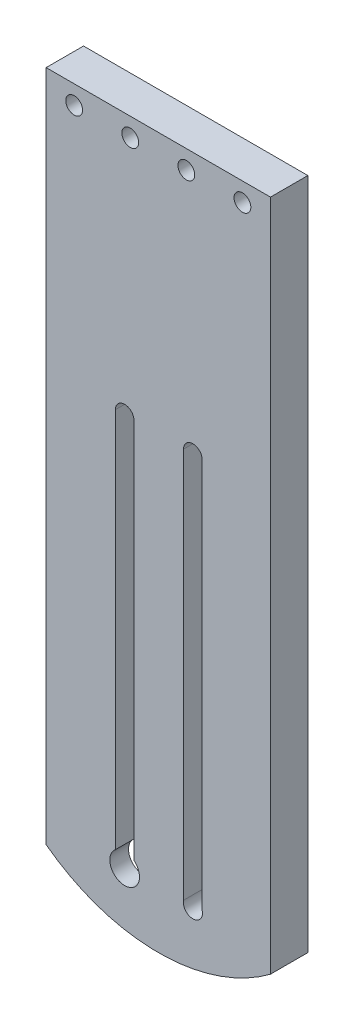
from build123d import *

# Parameters (mm, degrees)
EXTRUDE_1_DEPTH            = 10
HOLE_WIZARD_M4_D           = 4.5
HOLE_WIZARD_M4_CBORE_D     = 8
HOLE_WIZARD_M4_CBORE_DEPTH = 4
HOLE_WIZARD_1_4_201_D      = 5.1054
HOLE_WIZARD_3_8_161_D      = 7.9375
CUT_EXTRUDE_1_DEPTH        = 11
SKETCH_14_W                = 20.2
SKETCH_14_H                = 40
CUT_EXTRUDE_2_DEPTH        = 7
SKETCH_15_R                = 2
CUT_EXTRUDE_3_DEPTH        = 7
CUT_EXTRUDE_4_DEPTH        = 11
CUT_EXTRUDE_7_DEPTH        = 5
CUT_EXTRUDE_8_DEPTH        = 5
SKETCH_18_W                = 12.9
SKETCH_18_H                = 40
CUT_EXTRUDE_6_DEPTH        = 5
FILLET_1_R                 = 3


with BuildPart() as part:
    # Эскиз1 → Бобышка-Вытянуть1 (new body)
    with BuildSketch(Plane.XY):
        Polygon((0, 0), (60, 0), (60, -60), (60, -150), (60, -190), (0, -190), align=None)
    extrude(amount=EXTRUDE_1_DEPTH)

    # Цековка для винта с внутренним шестигранником M4 (through all)
    with Locations(Plane(origin=(-14.842707118, -41.655134189, 0), x_dir=(-1, 0, 0), z_dir=(0, 0, -1))):
        with Locations((-67.342707118, 36.655134189), (-52.342707118, 36.655134189), (-37.342707118, 36.655134189), (-22.342707118, 36.655134189)):
            CounterBoreHole(HOLE_WIZARD_M4_D / 2, HOLE_WIZARD_M4_CBORE_D / 2, HOLE_WIZARD_M4_CBORE_DEPTH)

    # Отверстие обработанное метчиком 1/4-201 (through all)
    with Locations(Plane(origin=(39.25, -175, 10), x_dir=(1, 0, 0), z_dir=(0, 0, 1))):
        with Locations((0, 0)):
            Hole(HOLE_WIZARD_1_4_201_D / 2)

    # Отверстие обработанное метчиком 3/8-161 (through all)
    with Locations(Plane(origin=(21, -175, 10), x_dir=(1, 0, 0), z_dir=(0, 0, 1))):
        with Locations((0, 0)):
            Hole(HOLE_WIZARD_3_8_161_D / 2)

    # Эскиз12 → Вырез-Вытянуть1 (cut, through all)
    with BuildSketch(Plane.XY.offset(10)):
        with BuildLine():
            Line((36.75, -175), (36.75, -70))
            ThreePointArc((36.75, -70), (39.25, -67.5), (41.75, -70))
            Line((41.75, -70), (41.75, -175))
            ThreePointArc((41.75, -175), (39.25, -177.5), (36.75, -175))
        make_face()
        with BuildLine():
            Line((18.5, -175), (18.5, -70))
            ThreePointArc((18.5, -70), (21, -67.5), (23.5, -70))
            Line((23.5, -70), (23.5, -175))
            ThreePointArc((23.5, -175), (21, -177.5), (18.5, -175))
        make_face()
    extrude(amount=-CUT_EXTRUDE_1_DEPTH, mode=Mode.SUBTRACT)

    # Эскиз14 → Вырез-Вытянуть2 (cut)
    with BuildSketch(Plane(origin=(0, 0, 0), x_dir=(-1, 0, 0), z_dir=(0, 0, -1))):
        with Locations((-30, -35)):
            Rectangle(SKETCH_14_W, SKETCH_14_H)
    extrude(amount=-CUT_EXTRUDE_2_DEPTH, mode=Mode.SUBTRACT)

    # Эскиз15 → Вырез-Вытянуть3 (cut)
    with BuildSketch(Plane(origin=(0, 0, 0), x_dir=(-1, 0, 0), z_dir=(0, 0, -1))):
        with Locations((-39.1, -54)):
            Circle(SKETCH_15_R)
        with Locations((-20.9, -54)):
            Circle(SKETCH_15_R)
    extrude(amount=-CUT_EXTRUDE_3_DEPTH, mode=Mode.SUBTRACT)

    # Эскиз16 → Вырез-Вытянуть4 (cut, through all)
    with BuildSketch(Plane(origin=(0, 0, 0), x_dir=(-1, 0, 0), z_dir=(0, 0, -1))):
        with BuildLine():
            Line((0, -180), (0, -195))
            Line((0, -195), (-60, -195))
            Line((-60, -195), (-60, -180))
            ThreePointArc((-60, -180), (-30, -190), (0, -180))
        make_face()
    extrude(amount=-CUT_EXTRUDE_4_DEPTH, mode=Mode.SUBTRACT)

    # Эскиз19 → Вырез-Вытянуть7 (cut)
    with BuildSketch(Plane(origin=(0, 0, 0), x_dir=(-1, 0, 0), z_dir=(0, 0, -1))):
        with BuildLine():
            Line((-57, -61), (-57, -177.416573868))
            ThreePointArc((-57, -177.416573868), (-55, -179.416573868), (-53, -177.416573868))
            Line((-53, -177.416573868), (-53, -61))
            ThreePointArc((-53, -61), (-55, -59), (-57, -61))
        make_face()
        with BuildLine():
            Line((-7, -61), (-7, -177.416573868))
            ThreePointArc((-7, -177.416573868), (-5, -179.416573868), (-3, -177.416573868))
            Line((-3, -177.416573868), (-3, -61))
            ThreePointArc((-3, -61), (-5, -59), (-7, -61))
        make_face()
    extrude(amount=-CUT_EXTRUDE_7_DEPTH, mode=Mode.SUBTRACT)

    # Эскиз20 → Вырез-Вытянуть8 (cut)
    with BuildSketch(Plane(origin=(0, 0, 0), x_dir=(-1, 0, 0), z_dir=(0, 0, -1))):
        with BuildLine():
            Line((-50, -59), (-50, -182.532340636))
            ThreePointArc((-50, -182.532340636), (-30, -187), (-10, -182.532340636))
            Line((-10, -182.532340636), (-10, -59))
            Line((-10, -59), (-50, -59))
        make_face()
    extrude(amount=-CUT_EXTRUDE_8_DEPTH, mode=Mode.SUBTRACT)

    # Эскиз18 → Вырез-Вытянуть6 (cut)
    with BuildSketch(Plane(origin=(0, 0, 0), x_dir=(-1, 0, 0), z_dir=(0, 0, -1))):
        with Locations((-50.55, -35)):
            Rectangle(SKETCH_18_W, SKETCH_18_H)
        with Locations((-9.45, -35)):
            Rectangle(SKETCH_18_W, SKETCH_18_H)
    extrude(amount=-CUT_EXTRUDE_6_DEPTH, mode=Mode.SUBTRACT)

    # Скругление1
    fillet_1_edges = [part.edges().sort_by_distance(p)[0] for p in [
        (19.9, -15, 3.5),
        (40.1, -15, 3.5),
        (37.367949192, -55, 3.5),
        (40.1, -52.267949192, 3.5),
        (19.9, -52.267949192, 3.5),
        (22.632050808, -55, 3.5),
        (50, -59, 2.5),
        (10, -59, 2.5),
        (10, -182.532340636, 2.5),
        (50, -182.532340636, 2.5),
        (57, -55, 2.5),
        (57, -15, 2.5),
        (44.1, -15, 2.5),
        (44.1, -55, 2.5),
        (15.9, -15, 2.5),
        (3, -15, 2.5),
        (3, -55, 2.5),
        (15.9, -55, 2.5),
    ]]
    fillet(fillet_1_edges, radius=FILLET_1_R)


solid = part.part
